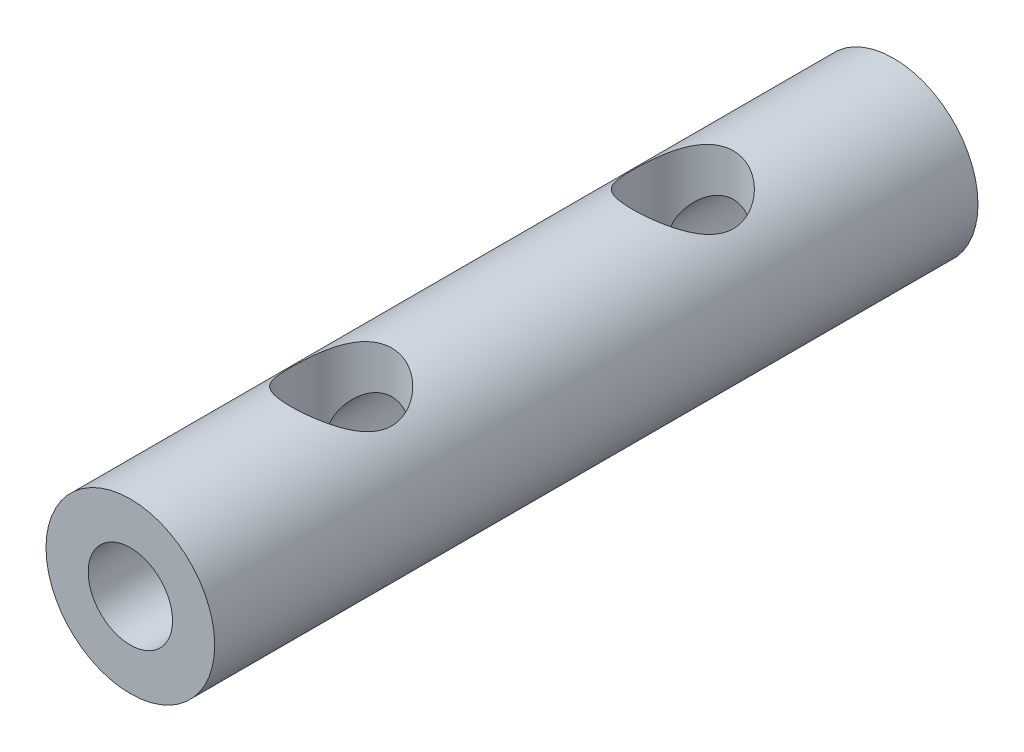
from build123d import *

# Parameters (mm, degrees)
SKETCH1_R           = 10
BOSS_EXTRUDE1_DEPTH = 90.5
SKETCH2_R           = 5
CUT_EXTRUDE1_DEPTH  = 91.5
SKETCH3_R           = 6
CUT_EXTRUDE2_DEPTH  = 21


with BuildPart() as part:
    # Sketch1 → Boss-Extrude1 (new body)
    with BuildSketch(Plane.XY):
        Circle(SKETCH1_R)
    extrude(amount=BOSS_EXTRUDE1_DEPTH)

    # Sketch2 → Cut-Extrude1 (cut, through all)
    with BuildSketch(Plane.XY.offset(90.5)):
        Circle(SKETCH2_R)
    extrude(amount=-CUT_EXTRUDE1_DEPTH, mode=Mode.SUBTRACT)

    # Sketch3 → Cut-Extrude2 (cut, through all)
    with BuildSketch(Plane(origin=(0, 10, 0), x_dir=(1, 0, 0), z_dir=(0, 1, 0))):
        with Locations((0, -25)):
            Circle(SKETCH3_R)
        with Locations((0, -65.5)):
            Circle(SKETCH3_R)
    extrude(amount=-CUT_EXTRUDE2_DEPTH, mode=Mode.SUBTRACT)


solid = part.part
